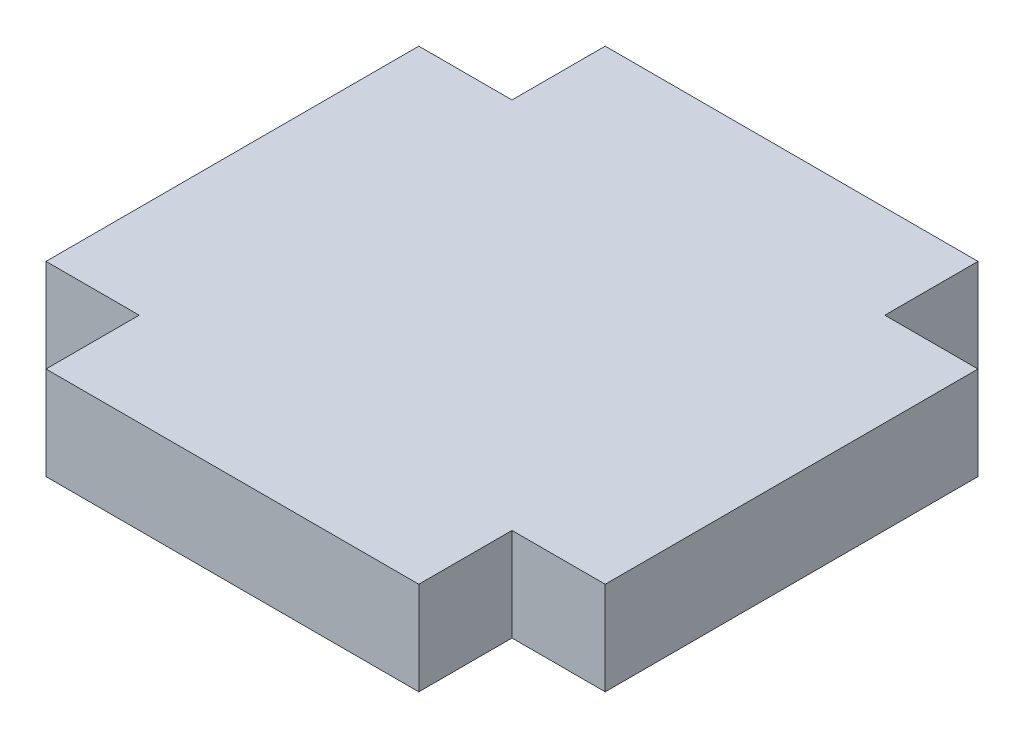
from build123d import *

# Parameters (mm, degrees)
BOSS_EXTRUDE1_DEPTH = 1.5875


with BuildPart() as part:
    # Sketch1 → Boss-Extrude1 (new body, symmetric)
    with BuildSketch(Plane(origin=(0, 0, 0), x_dir=(1, 0, 0), z_dir=(0, 1, 0))):
        Polygon((-9.525, 6.35), (-9.525, -6.35), (-6.35, -6.35), (-6.35, -9.525), (6.35, -9.525), (6.35, -6.35), (9.525, -6.35), (9.525, 6.35), (6.35, 6.35), (6.35, 9.525), (-6.35, 9.525), (-6.35, 6.35), align=None)
    extrude(amount=BOSS_EXTRUDE1_DEPTH, both=True)


solid = part.part
